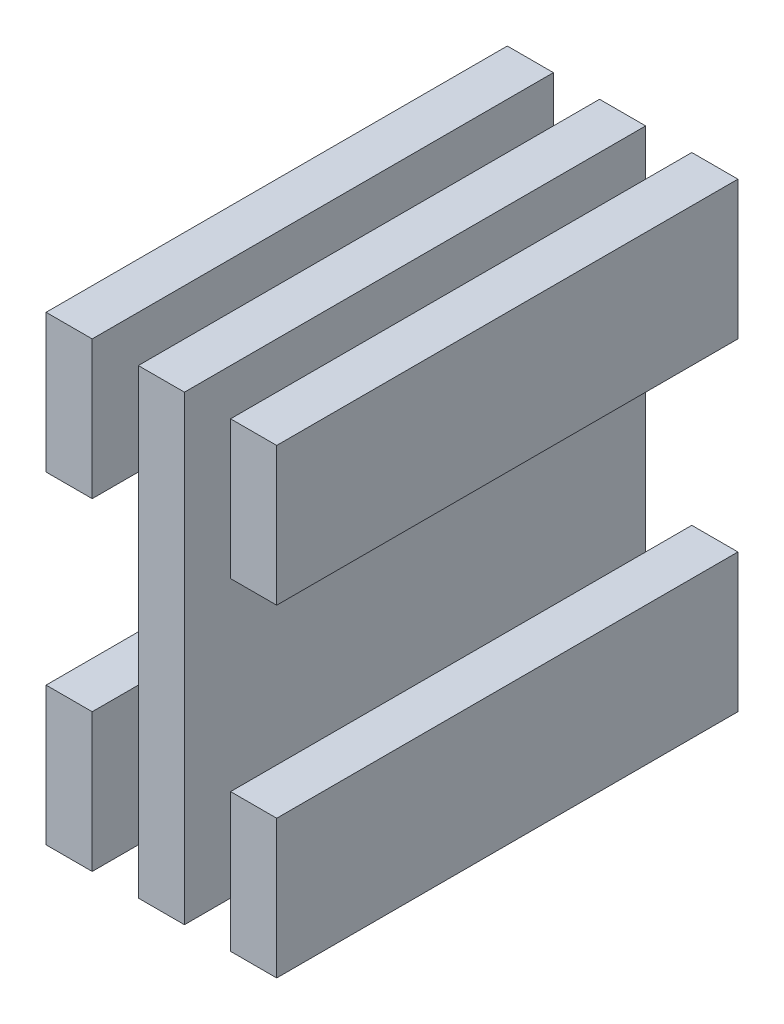
from build123d import *

# Parameters (mm, degrees)
SKETCH1_W             = 5
SKETCH1_H             = 50
BOSS_EXTRUDE1_DEPTH   = 50
BOSS_EXTRUDE1_2_DEPTH = 50
BOSS_EXTRUDE1_3_DEPTH = 50
SKETCH2_W             = 50
SKETCH2_H             = 20
CUT_EXTRUDE1_DEPTH    = 26


with BuildPart() as part:
    # Sketch1 → Boss-Extrude1 (new body)
    with BuildSketch(Plane(origin=(0, 0, 0), x_dir=(1, 0, 0), z_dir=(0, 1, 0))):
        with Locations((12.5, 25)):
            Rectangle(SKETCH1_W, SKETCH1_H)
    extrude(amount=BOSS_EXTRUDE1_DEPTH)


with BuildPart() as body_2:
    # Sketch1 → Boss-Extrude1 2 (new body)
    with BuildSketch(Plane(origin=(0, 0, 0), x_dir=(1, 0, 0), z_dir=(0, 1, 0))):
        with Locations((2.5, 25)):
            Rectangle(SKETCH1_W, SKETCH1_H)
    extrude(amount=BOSS_EXTRUDE1_2_DEPTH)


with BuildPart() as body_3:
    # Sketch1 → Boss-Extrude1 3 (new body)
    with BuildSketch(Plane(origin=(0, 0, 0), x_dir=(1, 0, 0), z_dir=(0, 1, 0))):
        with Locations((22.5, 25)):
            Rectangle(SKETCH1_W, SKETCH1_H)
    extrude(amount=BOSS_EXTRUDE1_3_DEPTH)


with BuildPart() as cut_extrude1_tool:
    # Sketch2 → Cut-Extrude1 (new body, through all)
    with BuildSketch(Plane(origin=(25, 0, 0), x_dir=(0, 0, -1), z_dir=(1, 0, 0))):
        with Locations((25, 25)):
            Rectangle(SKETCH2_W, SKETCH2_H)
    extrude(amount=-CUT_EXTRUDE1_DEPTH)


with BuildPart() as body_3_1:
    add(body_3.part)

    # Cut-Extrude1: cut by cut_extrude1_tool
    add(cut_extrude1_tool.part, mode=Mode.SUBTRACT)


with BuildPart() as body_2_1:
    add(body_2.part)

    # Cut-Extrude1: cut by cut_extrude1_tool
    add(cut_extrude1_tool.part, mode=Mode.SUBTRACT)


solid = Compound([part.part, body_3_1.part, body_2_1.part])
